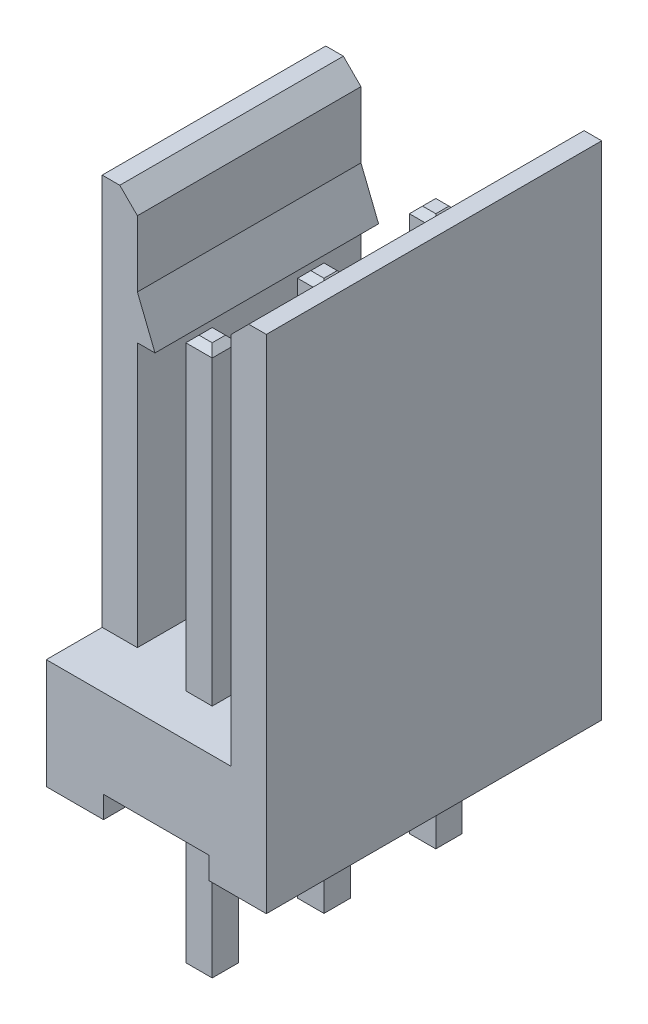
from build123d import *

# Parameters (mm, degrees)
BOSS_EXTRU_1_DEPTH      = 7.62
ESQUISSE3_W             = 0.8
ESQUISSE3_H             = 1.27
ENL_V_MAT_EXTRU_1_DEPTH = 8.9
ESQUISSE4_W             = 2.4
ESQUISSE4_H             = 0.5
ENL_V_MAT_EXTRU_2_DEPTH = 8.62
ESQUISSE2_W             = 0.6
ESQUISSE2_H             = 0.6
BOSS_EXTRU_2_DEPTH      = 3.5
BOSS_EXTRU_2_DEPTH_BACK = 9
BOSS_EXTRU_3_DEPTH      = 5.08
CHANFREIN4_SIZE         = 0.15
CHANFREIN5_SIZE         = 0.4


with BuildPart() as part:
    # Esquisse1 → Boss.-Extru.1 (new body)
    with BuildSketch(Plane.XY):
        Polygon((0, 11.4), (0, 0), (5, 0), (5, 11.4), (4.2, 11.4), (4.2, 2.5), (0.8, 2.5), (0.8, 11.4), align=None)
    extrude(amount=BOSS_EXTRU_1_DEPTH)

    # Esquisse3 → Enlèv. mat.-Extru.1 (cut)
    with BuildSketch(Plane(origin=(0, 11.4, 0), x_dir=(1, 0, 0), z_dir=(0, 1, 0))):
        with Locations((0.4, -0.635)):
            Rectangle(ESQUISSE3_W, ESQUISSE3_H)
        with Locations((0.4, -6.985)):
            Rectangle(ESQUISSE3_W, ESQUISSE3_H)
    extrude(amount=-ENL_V_MAT_EXTRU_1_DEPTH, mode=Mode.SUBTRACT)

    # Esquisse4 → Enlèv. mat.-Extru.2 (cut, through all)
    with BuildSketch(Plane.XY.offset(7.62)):
        with Locations((2.5, 0.25)):
            Rectangle(ESQUISSE4_W, ESQUISSE4_H)
    extrude(amount=-ENL_V_MAT_EXTRU_2_DEPTH, mode=Mode.SUBTRACT)

    # Esquisse2 → Boss.-Extru.2 (add, two sides)
    with BuildSketch(Plane.XZ.offset(-0.5)) as boss_extru_2_sk:
        with Locations((2.5, 6.35)):
            Rectangle(ESQUISSE2_W, ESQUISSE2_H)
        with Locations((2.5, 1.27)):
            Rectangle(ESQUISSE2_W, ESQUISSE2_H)
        with Locations((2.5, 3.81)):
            Rectangle(ESQUISSE2_W, ESQUISSE2_H)
    extrude(amount=BOSS_EXTRU_2_DEPTH)
    extrude(boss_extru_2_sk.sketch, amount=-BOSS_EXTRU_2_DEPTH_BACK)

    # Esquisse5 → Boss.-Extru.3 (add)
    with BuildSketch(Plane.XY.offset(6.35)):
        Polygon((0.8, 9.5), (1.2, 8.5), (0.8, 8.5), align=None)
    extrude(amount=-BOSS_EXTRU_3_DEPTH)

    # Chanfrein4
    chanfrein4_edges = [part.edges().sort_by_distance(p)[0] for p in [
        (2.8, 9.5, 3.81),
        (2.5, 9.5, 3.51),
        (2.2, 9.5, 3.81),
        (2.5, 9.5, 4.11),
        (2.8, -3, 3.81),
        (2.5, -3, 4.11),
        (2.2, -3, 3.81),
        (2.5, -3, 3.51),
        (2.8, 9.5, 6.35),
        (2.5, 9.5, 6.05),
        (2.2, 9.5, 6.35),
        (2.5, 9.5, 6.65),
        (2.8, -3, 6.35),
        (2.5, -3, 6.65),
        (2.2, -3, 6.35),
        (2.5, -3, 6.05),
        (2.8, 9.5, 1.27),
        (2.5, 9.5, 0.97),
        (2.2, 9.5, 1.27),
        (2.5, 9.5, 1.57),
        (2.8, -3, 1.27),
        (2.5, -3, 1.57),
        (2.2, -3, 1.27),
        (2.5, -3, 0.97),
    ]]
    chamfer(chanfrein4_edges, length=CHANFREIN4_SIZE)

    # Chanfrein5
    chanfrein5_edges = [part.edges().sort_by_distance(p)[0] for p in [
        (4.2, 11.4, 3.81),
        (0.8, 11.4, 3.81),
    ]]
    chamfer(chanfrein5_edges, length=CHANFREIN5_SIZE)


solid = part.part
